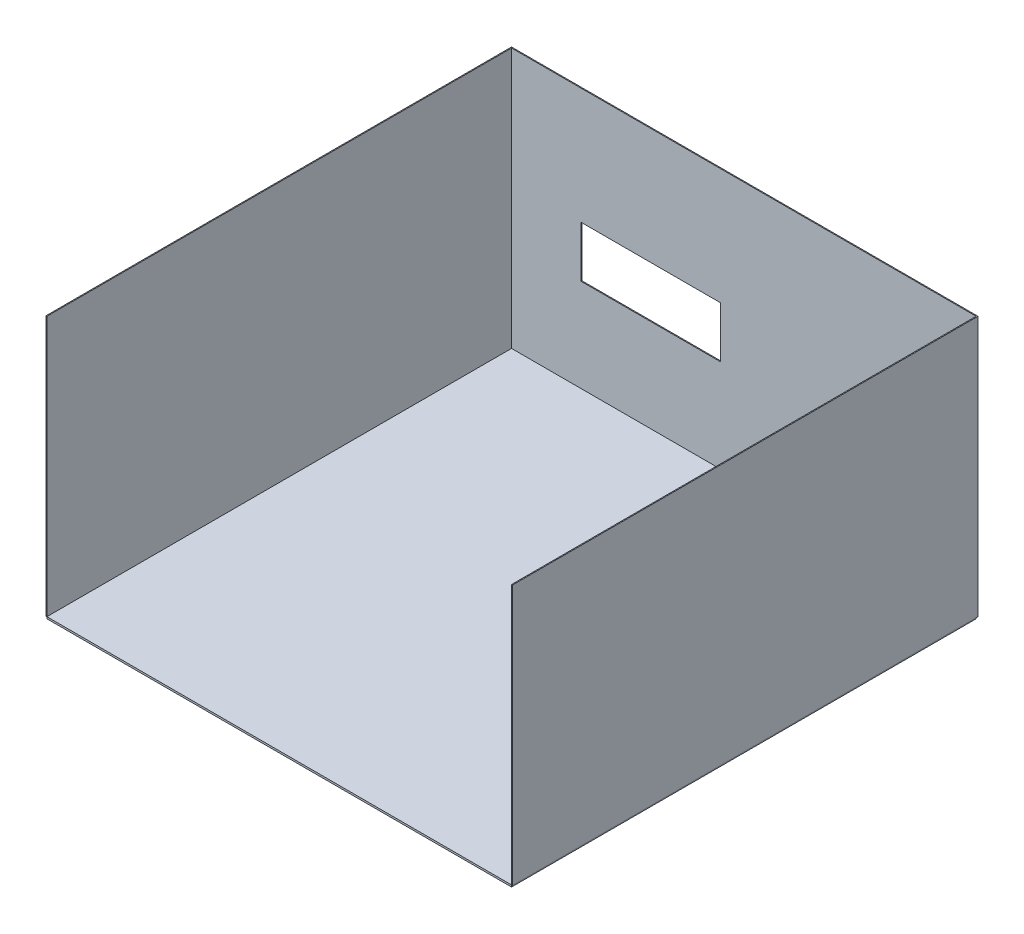
from build123d import *

# Parameters (mm, degrees)
SKETCH1_W           = 5000
SKETCH1_H           = 5000
BOSS_EXTRUDE1_DEPTH = 20
EXTRUDE_THIN1_DEPTH = 2800
SKETCH5_W           = 1500
SKETCH5_H           = 550
CUT_EXTRUDE1_DEPTH  = 10


with BuildPart() as part:
    # Sketch1 → Boss-Extrude1 (new body)
    with BuildSketch(Plane(origin=(0, 0, 0), x_dir=(1, 0, 0), z_dir=(0, 1, 0))):
        with Locations((-31200.616142501, 409.645456317)):
            Rectangle(SKETCH1_W, SKETCH1_H)
    extrude(amount=BOSS_EXTRUDE1_DEPTH)


with BuildPart() as body_2:
    # Sketch4 → Extrude-Thin1 (new body)
    with BuildSketch(Plane(origin=(0, 20, 0), x_dir=(1, 0, 0), z_dir=(0, 1, 0))):
        Polygon((-28700.616142501, -2090.354543683), (-28700.616142501, 2909.645456317), (-33700.616142501, 2909.645456317), (-33700.616142501, -2090.354543683), (-33710.616142501, -2090.354543683), (-33710.616142501, 2919.645456317), (-28690.616142501, 2919.645456317), (-28690.616142501, -2090.354543683), align=None)
    extrude(amount=EXTRUDE_THIN1_DEPTH)

    # Sketch5 → Cut-Extrude1 (cut)
    with BuildSketch(Plane.XY.offset(-2909.645456317)):
        with Locations((-32200.616142501, 1295)):
            Rectangle(SKETCH5_W, SKETCH5_H)
    extrude(amount=-CUT_EXTRUDE1_DEPTH, mode=Mode.SUBTRACT)


solid = Compound([part.part, body_2.part])
